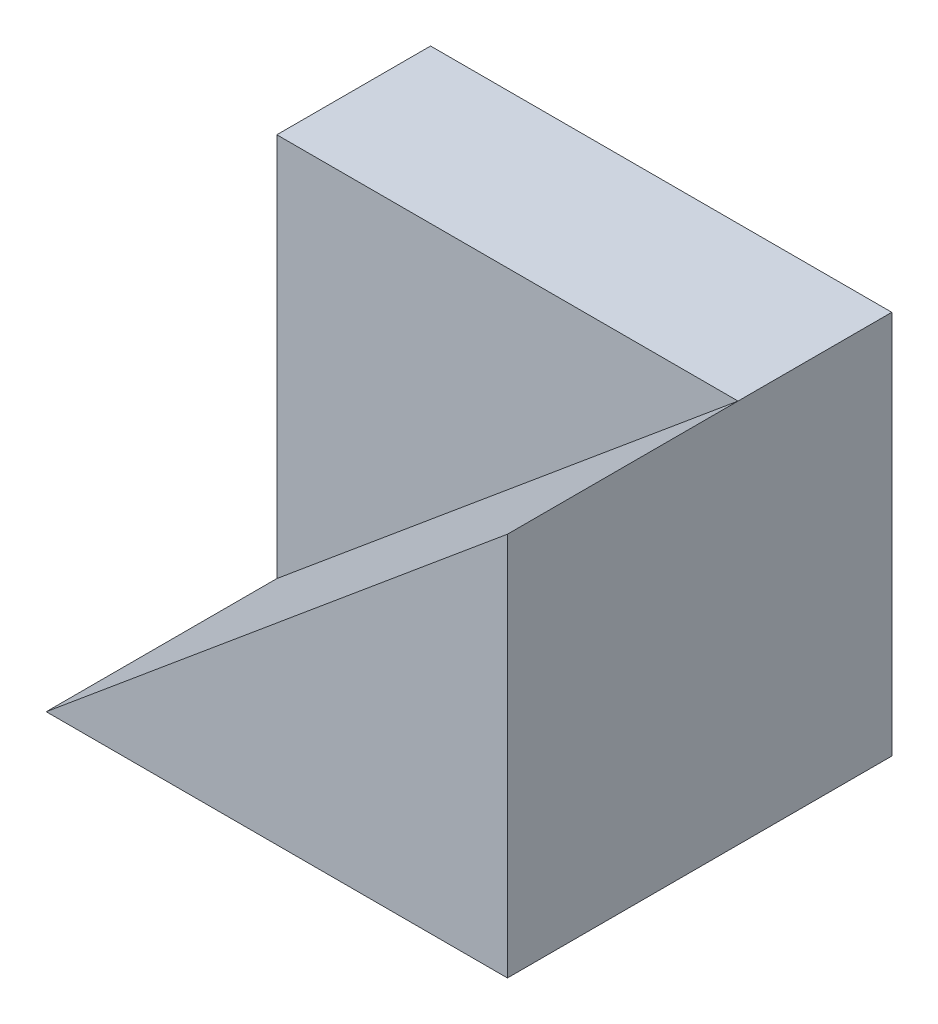
from build123d import *

# Parameters (mm, degrees)
SKETCH1_W           = 30
SKETCH1_H           = 25
BOSS_EXTRUDE1_DEPTH = 10
BOSS_EXTRUDE2_DEPTH = 15


with BuildPart() as part:
    # Sketch1 → Boss-Extrude1 (new body)
    with BuildSketch(Plane.XY):
        with Locations((-15, 12.5)):
            Rectangle(SKETCH1_W, SKETCH1_H)
    extrude(amount=BOSS_EXTRUDE1_DEPTH)

    # Sketch2 → Boss-Extrude2 (add)
    with BuildSketch(Plane.XY.offset(10)):
        Polygon((-30, 0), (0, 25), (0, 0), align=None)
    extrude(amount=BOSS_EXTRUDE2_DEPTH)


solid = part.part
